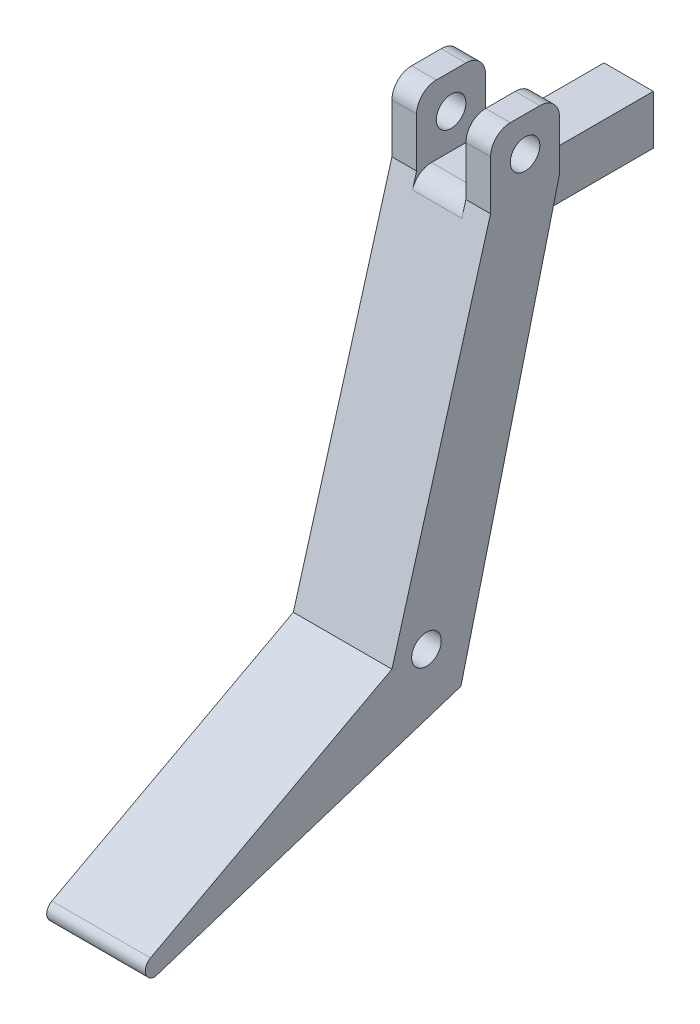
from build123d import *

# Parameters (mm, degrees)
SKETCH1_R           = 1.5
BOSS_EXTRUDE1_DEPTH = 10
FILLET1_R           = 1
SKETCH2_W           = 5
SKETCH2_H           = 7
CUT_EXTRUDE1_DEPTH  = 7
FILLET3_R           = 2
CUT_EXTRUDE2_DEPTH  = 20
SKETCH4_W           = 5
SKETCH4_H           = 17.5
BOSS_EXTRUDE3_DEPTH = 5


with BuildPart() as part:
    # Sketch1 → Boss-Extrude1 (new body)
    with BuildSketch(Plane(origin=(0, 0, 0), x_dir=(0, 0, -1), z_dir=(1, 0, 0))):
        Polygon((-37.823529412, -17.294117647), (-22.823529412, -17.294117647), (-2.823529412, -7.294117647), (7.176470588, 32.705882353), (7.176470588, 39.705882353), (0.176470588, 39.705882353), (0.176470588, 32.705882353), (-9.823529412, -2.294117647), align=None)
        with Locations((3.676470588, 36.205882353)):
            Circle(SKETCH1_R, mode=Mode.SUBTRACT)
        with Locations((-6.323529412, -2.294117647)):
            Circle(SKETCH1_R, mode=Mode.SUBTRACT)
    extrude(amount=BOSS_EXTRUDE1_DEPTH)

    # Fillet1
    fillet1_edges = [part.edges().sort_by_distance(p)[0] for p in [
        (5, -17.294117647, 37.823529412),
    ]]
    fillet(fillet1_edges, radius=FILLET1_R)

    # Sketch2 → Cut-Extrude1 (cut)
    with BuildSketch(Plane(origin=(0, 39.705882353, 0), x_dir=(1, 0, 0), z_dir=(0, 1, 0))):
        with Locations((5, 3.676470588)):
            Rectangle(SKETCH2_W, SKETCH2_H)
    extrude(amount=-CUT_EXTRUDE1_DEPTH, mode=Mode.SUBTRACT)

    # Fillet3
    fillet3_edges = [part.edges().sort_by_distance(p)[0] for p in [
        (8.75, 39.705882353, -0.176470588),
        (8.75, 39.705882353, -7.176470588),
        (1.25, 39.705882353, -0.176470588),
        (1.25, 39.705882353, -7.176470588),
        (5, 32.705882353, -0.176470588),
    ]]
    fillet(fillet3_edges, radius=FILLET3_R)

    # Sketch3 → Cut-Extrude2 (cut)
    with BuildSketch(Plane(origin=(10, 0, 0), x_dir=(0, 0, -1), z_dir=(1, 0, 0))):
        Polygon((-33.839212055, -17.294117647), (-2.823529412, -7.294117647), (-22.823529412, -17.294117647), align=None)
    extrude(amount=-CUT_EXTRUDE2_DEPTH, mode=Mode.SUBTRACT)

    # Sketch4 → Boss-Extrude3 (add)
    with BuildSketch(Plane(origin=(0, 32.705882353, 0), x_dir=(1, 0, 0), z_dir=(0, 1, 0))):
        with Locations((5, 10.435073414)):
            Rectangle(SKETCH4_W, SKETCH4_H)
    extrude(amount=-BOSS_EXTRUDE3_DEPTH)


solid = part.part
